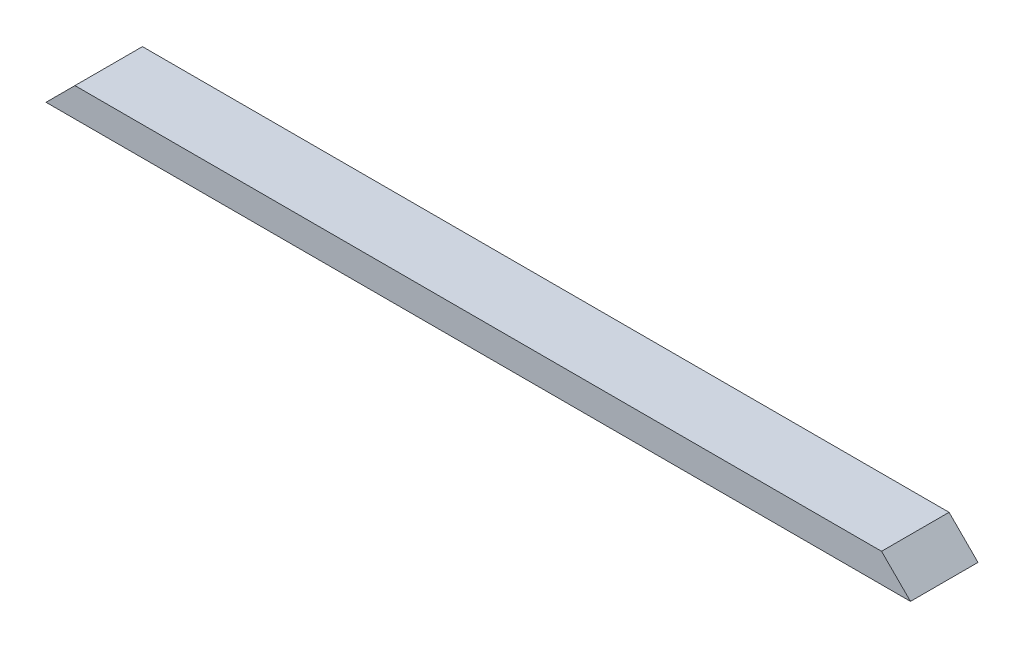
from build123d import *

# Parameters (mm, degrees)
SKETCH1_W           = 1138.2375
SKETCH1_H           = 88.9
BOSS_EXTRUDE1_DEPTH = 38.1
CUT_EXTRUDE1_DEPTH  = 89.9


with BuildPart() as part:
    # Sketch1 → Boss-Extrude1 (new body)
    with BuildSketch(Plane(origin=(0, 0, 0), x_dir=(1, 0, 0), z_dir=(0, 1, 0))):
        with Locations((569.11875, 44.45)):
            Rectangle(SKETCH1_W, SKETCH1_H)
    extrude(amount=BOSS_EXTRUDE1_DEPTH)

    # Sketch2 → Cut-Extrude1 (cut, through all)
    with BuildSketch(Plane.XY):
        Polygon((0, 0), (38.1, 38.1), (0, 38.1), align=None)
        Polygon((1138.2375, 0), (1138.2375, 38.1), (1100.1375, 38.1), align=None)
    extrude(amount=-CUT_EXTRUDE1_DEPTH, mode=Mode.SUBTRACT)


solid = part.part
